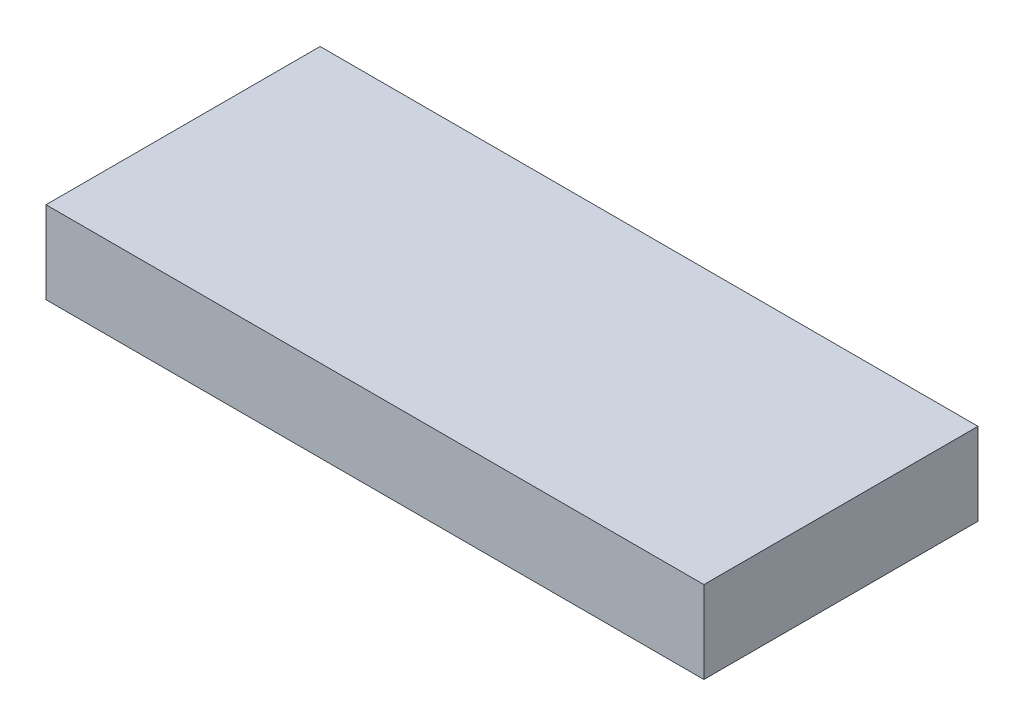
from build123d import *

# Parameters (mm, degrees)
SKETCH1_W           = 36
SKETCH1_H           = 15
BOSS_EXTRUDE1_DEPTH = 4.5


with BuildPart() as part:
    # Sketch1 → Boss-Extrude1 (new body)
    with BuildSketch(Plane(origin=(0, 0, 0), x_dir=(1, 0, 0), z_dir=(0, 1, 0))):
        with Locations((-17.951642274, 6.713439969)):
            Rectangle(SKETCH1_W, SKETCH1_H)
    extrude(amount=BOSS_EXTRUDE1_DEPTH)


solid = part.part
